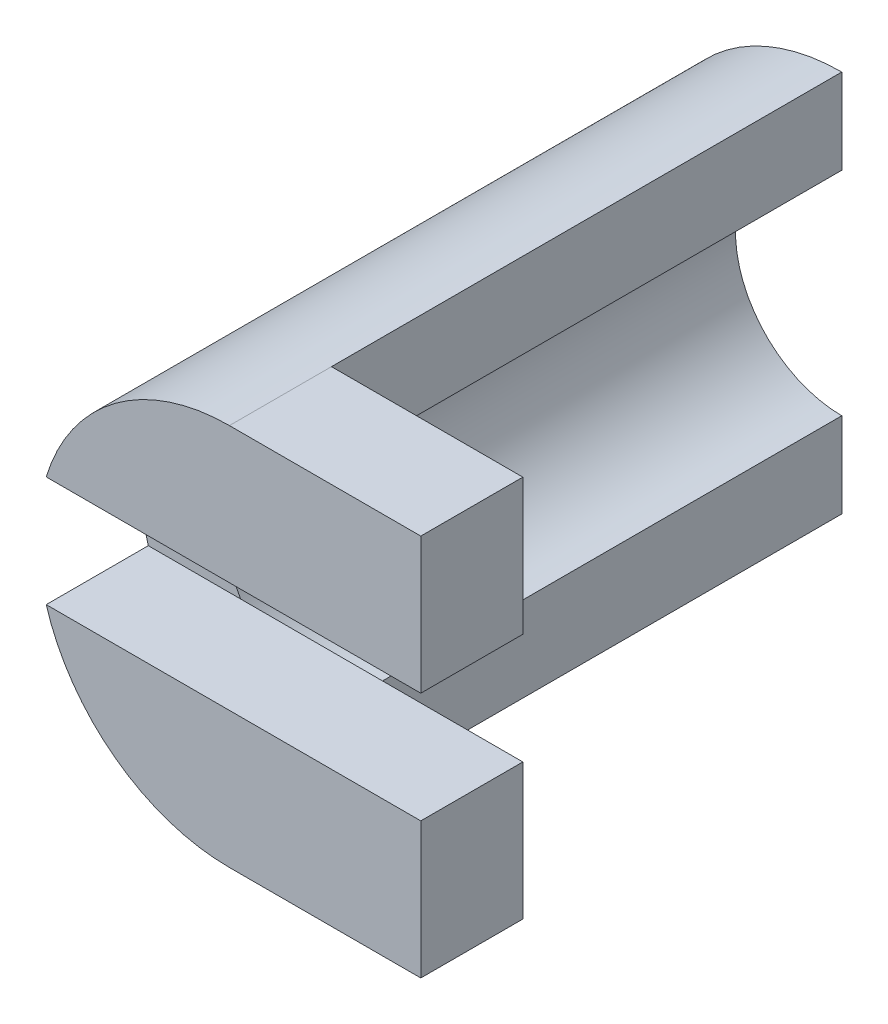
from build123d import *

# Parameters (mm, degrees)
EXTRUDE_1_DEPTH = 30
EXTRUDE_2_DEPTH = 6


with BuildPart() as part:
    # 草图1 → 凸台-拉伸1 (new body)
    with BuildSketch(Plane.XY):
        with BuildLine():
            Line((0, 6.25), (0, 11.25))
            ThreePointArc((0, 11.25), (-11.25, 0), (0, -11.25))
            Line((0, -11.25), (0, -6.25))
            ThreePointArc((0, -6.25), (-6.25, 0), (0, 6.25))
        make_face()
    extrude(amount=EXTRUDE_1_DEPTH)

    # 草图2 → 凸台-拉伸2 (add)
    with BuildSketch(Plane.XY.offset(30)):
        with BuildLine():
            Line((0, 6.25), (0, 11.25))
            ThreePointArc((0, 11.25), (-6.708203932, 9.031195934), (-10.770329614, 3.25))
            Line((-10.770329614, 3.25), (-5.338539126, 3.25))
            ThreePointArc((-5.338539126, 3.25), (-3.061862178, 5.448623679), (0, 6.25))
        make_face()
        with BuildLine():
            Line((11.25, 3.25), (11.25, 11.25))
            Line((11.25, 11.25), (0, 11.25))
            Line((0, 11.25), (0, 6.25))
            ThreePointArc((0, 6.25), (-3.061862178, 5.448623679), (-5.338539126, 3.25))
            Line((-5.338539126, 3.25), (11.25, 3.25))
        make_face()
        with BuildLine():
            ThreePointArc((0, -6.25), (-3.061862178, -5.448623679), (-5.338539126, -3.25))
            Line((-5.338539126, -3.25), (-10.770329614, -3.25))
            ThreePointArc((-10.770329614, -3.25), (-6.708203932, -9.031195934), (0, -11.25))
            Line((0, -11.25), (0, -6.25))
        make_face()
        with BuildLine():
            Line((11.25, -11.25), (11.25, -3.25))
            Line((11.25, -3.25), (-5.338539126, -3.25))
            ThreePointArc((-5.338539126, -3.25), (-3.061862178, -5.448623679), (0, -6.25))
            Line((0, -6.25), (0, -11.25))
            Line((0, -11.25), (11.25, -11.25))
        make_face()
    extrude(amount=EXTRUDE_2_DEPTH)


solid = part.part
